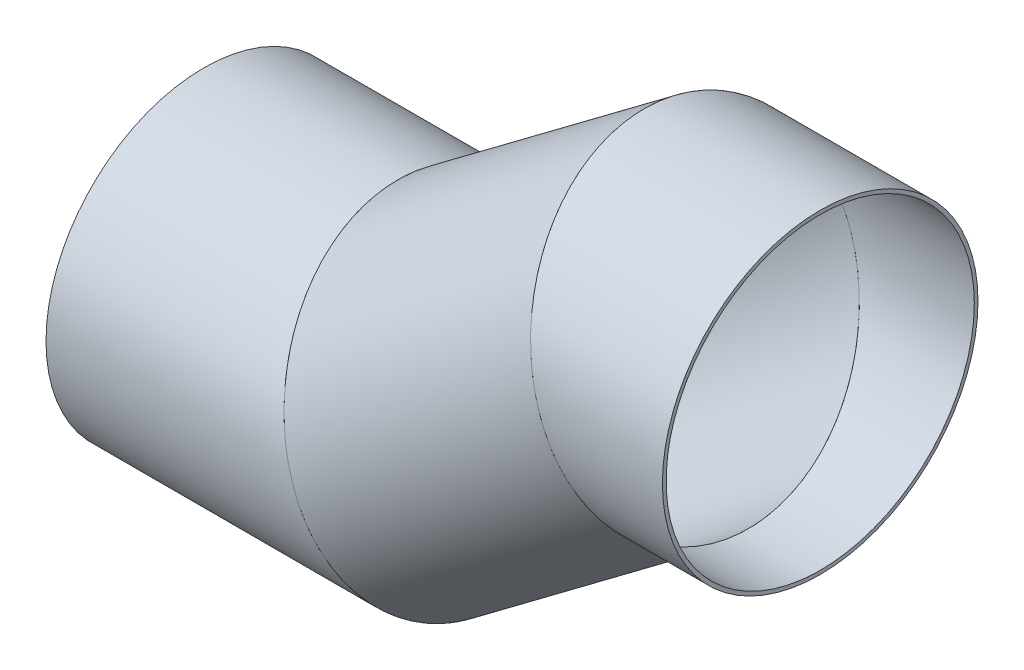
from build123d import *

# Parameters (mm, degrees)
SKETCH1_R                = 128
SKETCH1_R_2              = 125
STRUKTURBAUTEIL1_DEPTH   = 261.339778661
SKETCH1_ON_SEGMENT_2_R   = 128
SKETCH1_ON_SEGMENT_2_R_2 = 125
STRUKTURBAUTEIL1_2_DEPTH = 372.679557323
SKETCH1_ON_SEGMENT_3_R   = 128
SKETCH1_ON_SEGMENT_3_R_2 = 125
STRUKTURBAUTEIL1_3_DEPTH = 161.339778661


with BuildPart() as part:
    # Sketch1 → Strukturbauteil1 (new body)
    with BuildSketch(Plane.YZ):
        Circle(SKETCH1_R)
        Circle(SKETCH1_R_2, mode=Mode.SUBTRACT)
    extrude(amount=STRUKTURBAUTEIL1_DEPTH)

    # Strukturbauteil1 mitre 1
    split(bisect_by=Plane(origin=(200, 0, 0), x_dir=(0.316227766, -0.948683298, 0), z_dir=(-0.948683298, -0.316227766, 0)), keep=Keep.TOP)


with BuildPart() as body_2:
    # Sketch1 on segment 2 (carried to segment 2) → Strukturbauteil1 2 (new body)
    with BuildSketch(Plane(origin=(150.928177071, -36.803867197, 0), x_dir=(-0.6, 0.8, 0), z_dir=(0.8, 0.6, 0))):
        Circle(SKETCH1_ON_SEGMENT_2_R)
        Circle(SKETCH1_ON_SEGMENT_2_R_2, mode=Mode.SUBTRACT)
    extrude(amount=STRUKTURBAUTEIL1_2_DEPTH)

    # Strukturbauteil1 2 mitre 1
    split(bisect_by=Plane(origin=(200, 0, 0), x_dir=(-0.316227766, 0.948683298, 0), z_dir=(0.948683298, 0.316227766, 0)), keep=Keep.TOP)

    # Strukturbauteil1 2 mitre 2
    split(bisect_by=Plane(origin=(400, 150, 0), x_dir=(0.316227766, -0.948683298, 0), z_dir=(-0.948683298, -0.316227766, 0)), keep=Keep.TOP)


with BuildPart() as body_3:
    # Sketch1 on segment 3 (carried to segment 3) → Strukturbauteil1 3 (new body)
    with BuildSketch(Plane(origin=(338.660221339, 150, 0), x_dir=(0, 1, 0), z_dir=(1, 0, 0))):
        Circle(SKETCH1_ON_SEGMENT_3_R)
        Circle(SKETCH1_ON_SEGMENT_3_R_2, mode=Mode.SUBTRACT)
    extrude(amount=STRUKTURBAUTEIL1_3_DEPTH)

    # Strukturbauteil1 3 mitre 1
    split(bisect_by=Plane(origin=(400, 150, 0), x_dir=(-0.316227766, 0.948683298, 0), z_dir=(0.948683298, 0.316227766, 0)), keep=Keep.TOP)


solid = Compound([part.part, body_2.part, body_3.part])
